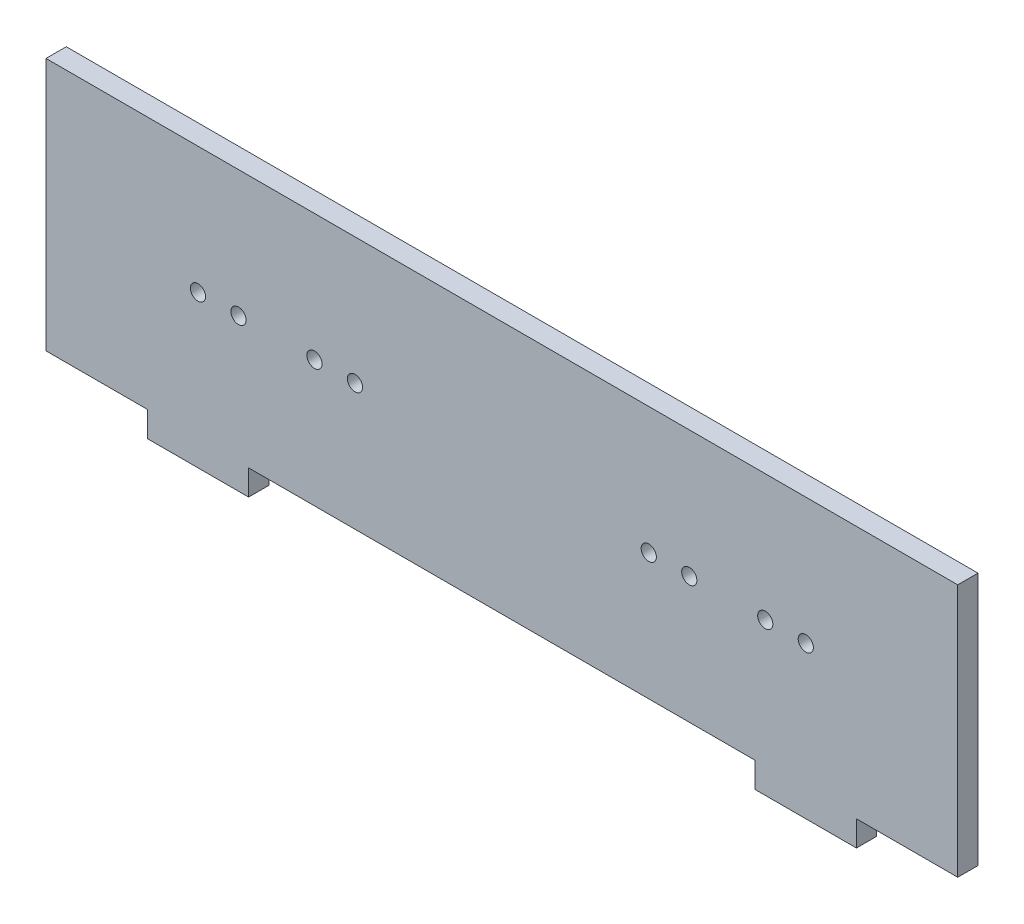
from build123d import *

# Parameters (mm, degrees)
SKETCH1_R           = 1.5
BOSS_EXTRUDE1_DEPTH = 4


with BuildPart() as part:
    # Sketch1 → Boss-Extrude1 (new body)
    with BuildSketch(Plane.XY):
        Polygon((-47.299357945, -31.117125984), (52.700642055, -31.117125984), (52.700642055, -36.117125984), (72.700642055, -36.117125984), (72.700642055, -31.117125984), (92.700642055, -31.117125984), (92.700642055, 18.882874016), (-87.299357945, 18.882874016), (-87.299357945, -31.117125984), (-67.299357945, -31.117125984), (-67.299357945, -36.117125984), (-47.299357945, -36.117125984), align=None)
        with Locations((-57.299357945, -6.117125984)):
            Circle(SKETCH1_R, mode=Mode.SUBTRACT)
        with Locations((62.700642055, -6.117125984)):
            Circle(SKETCH1_R, mode=Mode.SUBTRACT)
        with Locations((-49.299357945, -6.117125984)):
            Circle(SKETCH1_R, mode=Mode.SUBTRACT)
        with Locations((54.700642055, -6.117125984)):
            Circle(SKETCH1_R, mode=Mode.SUBTRACT)
        with Locations((-34.299357945, -6.117125984)):
            Circle(SKETCH1_R, mode=Mode.SUBTRACT)
        with Locations((-26.299357945, -6.117125984)):
            Circle(SKETCH1_R, mode=Mode.SUBTRACT)
        with Locations((39.700642055, -6.117125984)):
            Circle(SKETCH1_R, mode=Mode.SUBTRACT)
        with Locations((31.700642055, -6.117125984)):
            Circle(SKETCH1_R, mode=Mode.SUBTRACT)
    extrude(amount=BOSS_EXTRUDE1_DEPTH)


solid = part.part
